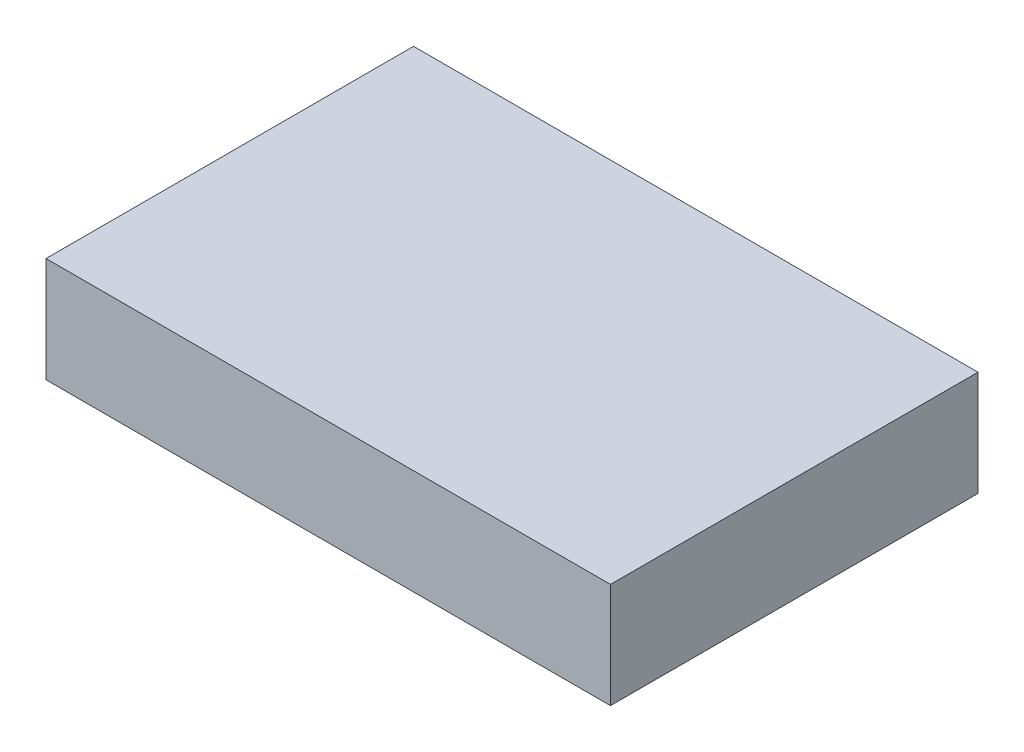
from build123d import *

# Parameters (mm, degrees)
SKETCH1_W           = 136.525
SKETCH1_H           = 88.9
BOSS_EXTRUDE1_DEPTH = 25.4


with BuildPart() as part:
    # Sketch1 → Boss-Extrude1 (new body)
    with BuildSketch(Plane(origin=(0, 0, 0), x_dir=(1, 0, 0), z_dir=(0, 1, 0))):
        Rectangle(SKETCH1_W, SKETCH1_H)
    extrude(amount=BOSS_EXTRUDE1_DEPTH)


solid = part.part
